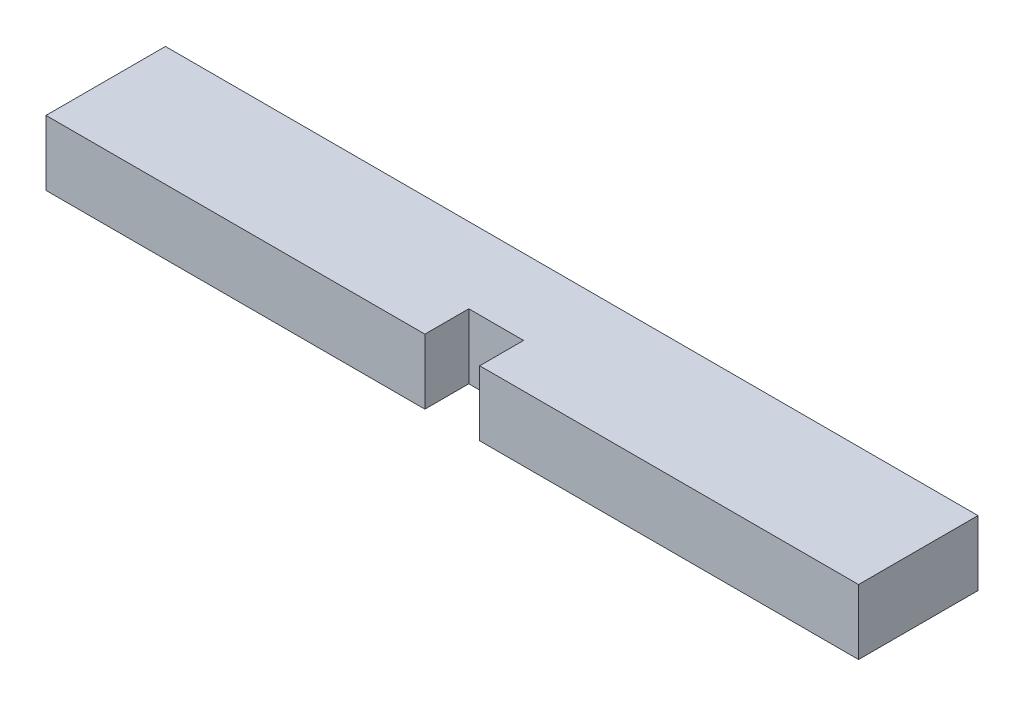
from build123d import *

# Parameters (mm, degrees)
SKETCH2_W               = 58.7502
SKETCH2_H               = 8.636
BOSS_EXTRUDE1_DEPTH     = 4.699
CUT_EXTRUDE1_DEPTH      = 1
CUT_EXTRUDE1_DEPTH_BACK = 3.175


with BuildPart() as part:
    # Sketch2 → Boss-Extrude1 (new body)
    with BuildSketch(Plane(origin=(0, 0, 0), x_dir=(1, 0, 0), z_dir=(0, 1, 0))):
        with Locations((-0.882327606, -0.31486737)):
            Rectangle(SKETCH2_W, SKETCH2_H)
    extrude(amount=BOSS_EXTRUDE1_DEPTH)

    # Sketch5 → Cut-Extrude1 (cut, two sides)
    with BuildSketch(Plane.XY.offset(4.63286737)) as cut_extrude1_sk:
        Polygon((-0.882327606, 0), (-2.863527606, 0), (-2.863527606, 4.699), (1.098872394, 4.699), (1.098872394, 0), align=None)
    extrude(amount=CUT_EXTRUDE1_DEPTH, mode=Mode.SUBTRACT)
    extrude(cut_extrude1_sk.sketch, amount=-CUT_EXTRUDE1_DEPTH_BACK, mode=Mode.SUBTRACT)


solid = part.part
